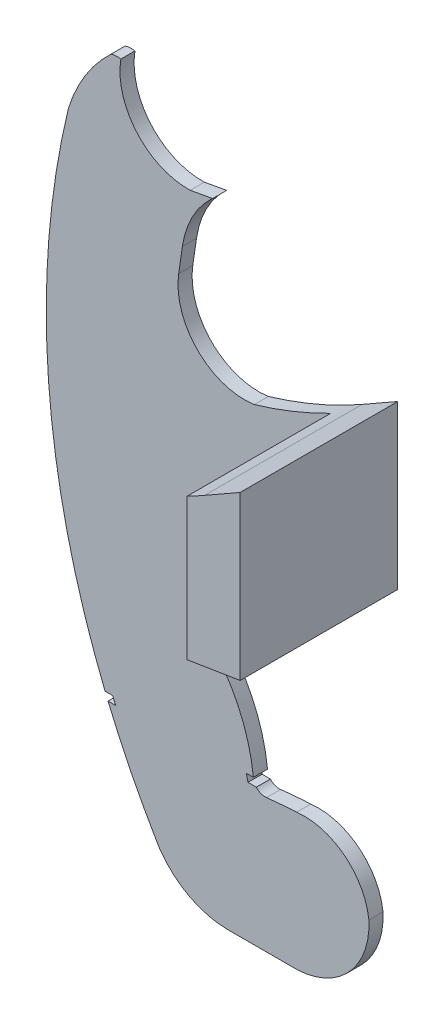
from build123d import *

# Parameters (mm, degrees)
BOSS_EXTRUDE2_DEPTH = 3
BOSS_EXTRUDE3_DEPTH = 30.5


with BuildPart() as part:
    # Sketch1 → Boss-Extrude2 (new body)
    with BuildSketch(Plane.XY):
        with BuildLine():
            Line((13.275380686, 31.205054945), (14.898132017, 31.200709019))
            Line((14.898132017, 31.200709019), (15.525048851, 29.699024681))
            Line((15.525048851, 29.699024681), (13.895725818, 29.703388206))
            ThreePointArc((13.895725818, 29.703388206), (18.832488619, 18.980593631), (24.505317159, 8.628349101))
            ThreePointArc((24.505317159, 8.628349101), (24.86546573, 8.055516696), (25.253864185, 7.501449375))
            ThreePointArc((25.253864185, 7.501449375), (31.492395544, 2.238754737), (39.432559358, 0.349567888))
            Line((39.432559358, 0.349567888), (54.166964146, 0.349567888))
            ThreePointArc((54.166964146, 0.349567888), (65.260793251, 5.589158017), (69.367502095, 17.15035568))
            ThreePointArc((69.367502095, 17.15035568), (64.201860596, 26.406348327), (54.004278297, 29.298850229))
            ThreePointArc((54.004278297, 29.298850229), (50.794421974, 29.086613139), (47.592527294, 28.776624992))
            ThreePointArc((47.592527294, 28.776624992), (46.406851761, 28.931308018), (45.428630625, 29.618939254))
            Line((45.428630625, 29.618939254), (43.664188783, 29.623664644))
            Line((43.664188783, 29.623664644), (43.305228514, 31.124631363))
            Line((43.305228514, 31.124631363), (44.814654419, 31.120588936))
            ThreePointArc((44.814654419, 31.120588936), (41.465663123, 42.879415537), (34.373869876, 52.838944354))
            ThreePointArc((34.373869876, 52.838944354), (31.77008993, 61.224226607), (35.075221649, 69.358643168))
            ThreePointArc((35.075221649, 69.358643168), (36.634181143, 70.853545892), (38.565369315, 71.820810645))
            ThreePointArc((38.565369315, 71.820810645), (41.657810048, 72.796166819), (44.793456308, 73.622140114))
            Line((44.793456308, 73.622140114), (49.906358238, 74.39986774))
            Line((49.906358238, 74.39986774), (72.499029275, 78.04718712))
            Line((72.499029275, 78.04718712), (72.499029275, 112.666688298))
            Line((72.499029275, 112.666688298), (64.965959637, 108.371234093))
            ThreePointArc((64.965959637, 108.371234093), (55.215260948, 103.529752912), (44.974426149, 99.836330705))
            ThreePointArc((44.974426149, 99.836330705), (32.918019246, 103.856141001), (28.925028873, 115.921456997))
            Line((28.925028873, 115.921456997), (29.712339951, 121.309986069))
            ThreePointArc((29.712339951, 121.309986069), (31.21062393, 126.530705767), (34.041547196, 131.166074417))
            ThreePointArc((34.041547196, 131.166074417), (34.181825554, 131.336695356), (34.323954998, 131.505777418))
            ThreePointArc((34.323954998, 131.505777418), (35.033278252, 132.297306273), (35.783119531, 133.050562846))
            ThreePointArc((35.783119531, 133.050562846), (35.963964723, 133.201914626), (36.140056994, 133.358770791))
            Line((36.140056994, 133.358770791), (31.386106103, 132.498519796))
            ThreePointArc((31.386106103, 132.498519796), (20.056581392, 137.416407931), (16.627117574, 149.281589422))
            ThreePointArc((16.627117574, 149.281589422), (15.570836478, 149.356522247), (14.534507264, 149.138883925))
            ThreePointArc((14.534507264, 149.138883925), (11.661008479, 146.078583559), (9.194011926, 142.682061573))
            ThreePointArc((9.194011926, 142.682061573), (7.06412615, 138.77022346), (5.473593477, 134.609803211))
            ThreePointArc((5.473593477, 134.609803211), (1.252330233, 82.294620281), (13.275380686, 31.205054945))
        make_face()
    extrude(amount=BOSS_EXTRUDE2_DEPTH)

    # Sketch2 → Boss-Extrude3 (add)
    with BuildSketch(Plane.XY.offset(3)):
        with BuildLine():
            Line((61.236736711, 76.229023262), (61.236736711, 106.35376845))
            ThreePointArc((61.236736711, 106.35376845), (63.112611761, 107.341680879), (64.965959637, 108.371234093))
            Line((64.965959637, 108.371234093), (72.499029275, 112.666688298))
            Line((72.499029275, 112.666688298), (72.499029275, 78.04718712))
            Line((72.499029275, 78.04718712), (61.236736711, 76.229023262))
        make_face()
    extrude(amount=BOSS_EXTRUDE3_DEPTH)


solid = part.part
